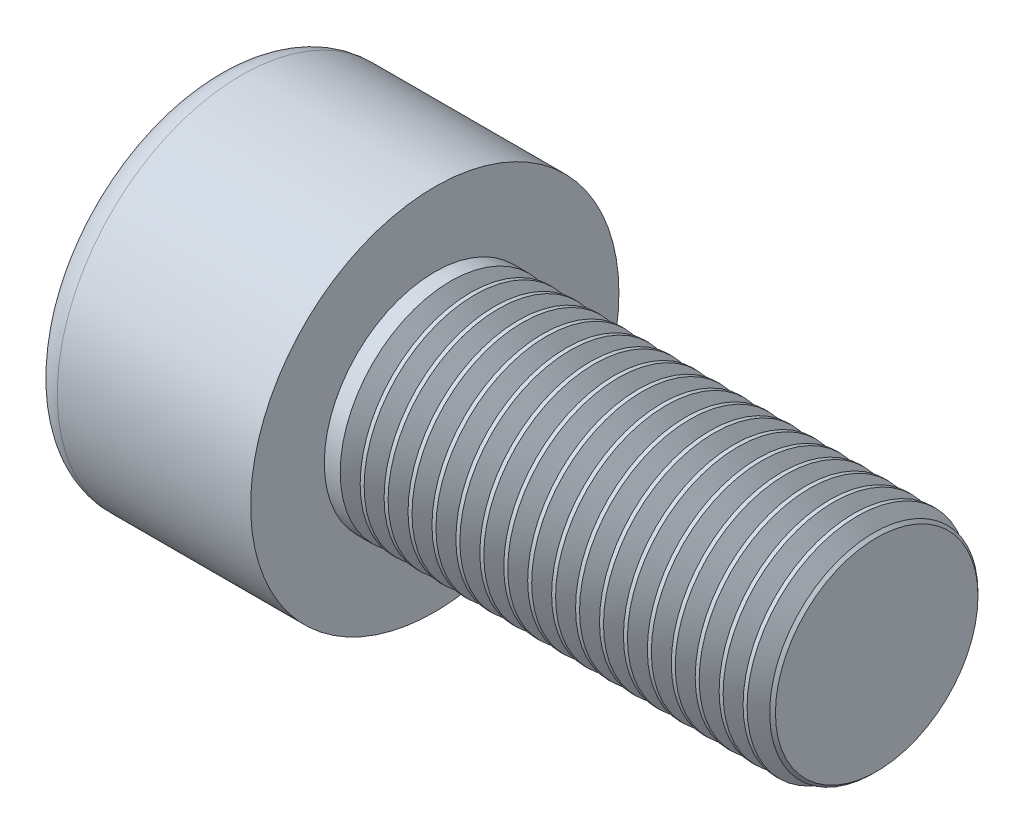
from build123d import *

# Parameters (mm, degrees)
SKETCH1_R           = 5
BASEHEAD_DEPTH      = 6
SKETCH2_R           = 3
BASEBODY_DEPTH      = 12
HEXAGONSOCKET_DEPTH = 3
TOPFILLET_R         = 0.75
CHAMFER1_SIZE       = 0.25
LPATTERN10_COUNT    = 18
LPATTERN10_PITCH    = 0.6498


with BuildPart() as part:
    # Sketch1 → BaseHead (new body)
    with BuildSketch(Plane(origin=(0, 0, 0), x_dir=(0, 0, -1), z_dir=(1, 0, 0))):
        Circle(SKETCH1_R)
    extrude(amount=BASEHEAD_DEPTH)

    # Sketch2 → BaseBody (add)
    with BuildSketch(Plane(origin=(6, 0, 0), x_dir=(0, 0, -1), z_dir=(1, 0, 0))):
        Circle(SKETCH2_R)
    extrude(amount=BASEBODY_DEPTH)

    # Sketch3 → HexagonSocket (cut)
    with BuildSketch(Plane(origin=(0, 0, 0), x_dir=(0, 0, -1), z_dir=(1, 0, 0))):
        Polygon((2.886751346, 0), (1.443375673, 2.5), (-1.443375673, 2.5), (-2.886751346, 0), (-1.443375673, -2.5), (1.443375673, -2.5), align=None)
    extrude(amount=HEXAGONSOCKET_DEPTH, mode=Mode.SUBTRACT)

    # Sketch4 → Cut-Revolve1 (revolve, cut)
    with BuildSketch(Plane(origin=(-4.19613823, 0.75, 0), x_dir=(-1, 0, 0), z_dir=(0, 0, 1))):
        Polygon((-7.19613823, 3.25), (-8.639513903, 0.75), (-7.19613823, 0.75), align=None)
    revolve(axis=Axis((0.838992387, 0, 0), (-1, 0, 0)), mode=Mode.SUBTRACT)

    # TopFillet
    topfillet_edges = [part.edges().sort_by_distance(p)[0] for p in [
        (0, 0, 5),
    ]]
    fillet(topfillet_edges, radius=TOPFILLET_R)

    # Chamfer1
    chamfer1_edges = [part.edges().sort_by_distance(p)[0] for p in [
        (18, 0, 3),
    ]]
    chamfer(chamfer1_edges, length=CHAMFER1_SIZE)

    # Sketch5 → Cut-Revolve10 (revolve, cut)
    with BuildSketch(Plane.XY):
        Polygon((17.75, 2.531047244), (18.02075, 3), (18.02075, 3.5415), (17.47925, 3.5415), (17.47925, 3), align=None)
    cut_revolve10 = revolve(axis=Axis((0, 0, 0), (1, 0, 0)), mode=Mode.SUBTRACT)

    # LPattern10: Cut-Revolve10 ×18
    with Locations(*[(-i * LPATTERN10_PITCH, 0, 0) for i in range(1, LPATTERN10_COUNT)]):
        add(cut_revolve10, mode=Mode.SUBTRACT)


solid = part.part
